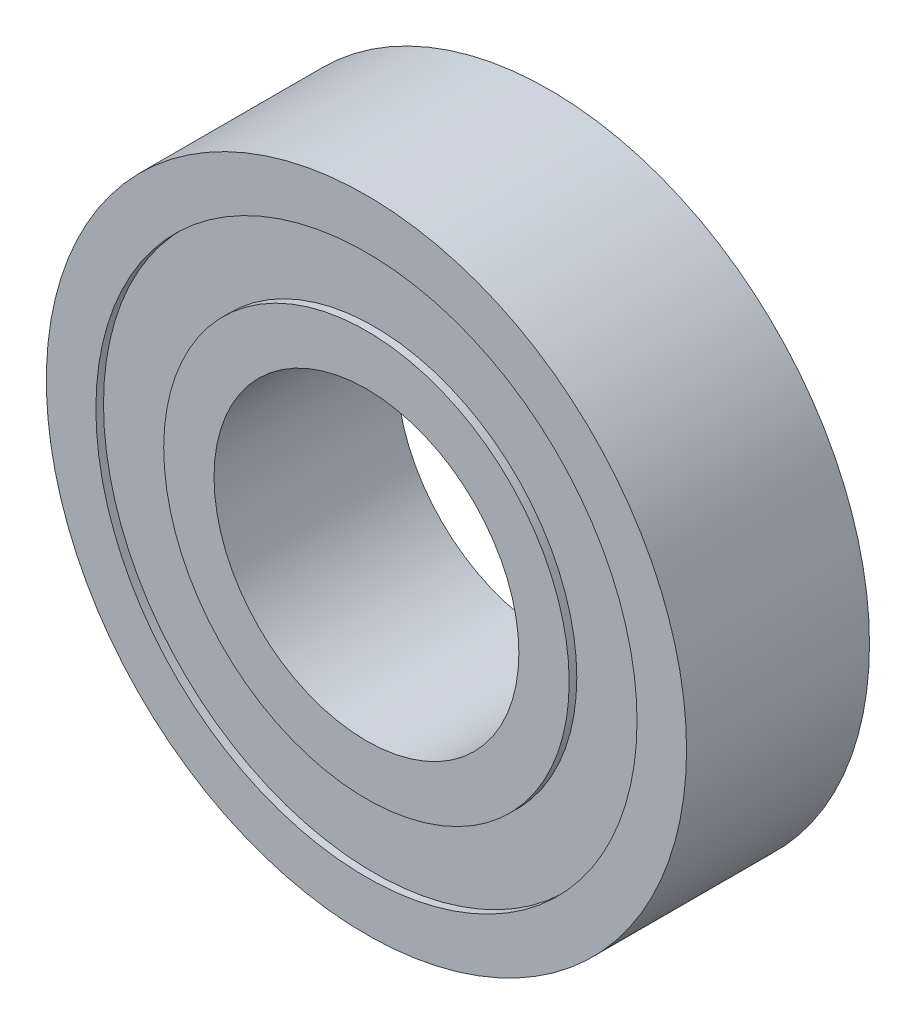
from build123d import *

# Parameters (mm, degrees)
SKETCH_1_R          = 21
EXTRUDE_1_DEPTH     = 6
SKETCH_3_R          = 10
CUT_EXTRUDE_1_DEPTH = 13
SKETCH_2_R          = 17.75
SKETCH_2_R_2        = 13.3
CUT_EXTRUDE_2_DEPTH = 0.5


with BuildPart() as part:
    # 草圖1 → 填料-伸長1 (new body, symmetric)
    with BuildSketch(Plane.XY):
        Circle(SKETCH_1_R)
    extrude(amount=EXTRUDE_1_DEPTH, both=True)

    # 草圖3 → 除料-伸長1 (cut, through all)
    with BuildSketch(Plane.XY.offset(6)):
        Circle(SKETCH_3_R)
    extrude(amount=-CUT_EXTRUDE_1_DEPTH, mode=Mode.SUBTRACT)

    # 草圖2 → 除料-伸長2 (cut)
    with BuildSketch(Plane.XY.offset(6)):
        Circle(SKETCH_2_R)
        Circle(SKETCH_2_R_2, mode=Mode.SUBTRACT)
    cut_extrude_2 = extrude(amount=-CUT_EXTRUDE_2_DEPTH, mode=Mode.SUBTRACT)

    # 鏡射1: 除料-伸長2 across plane
    add(cut_extrude_2.mirror(Plane.XY), mode=Mode.SUBTRACT)


solid = part.part
